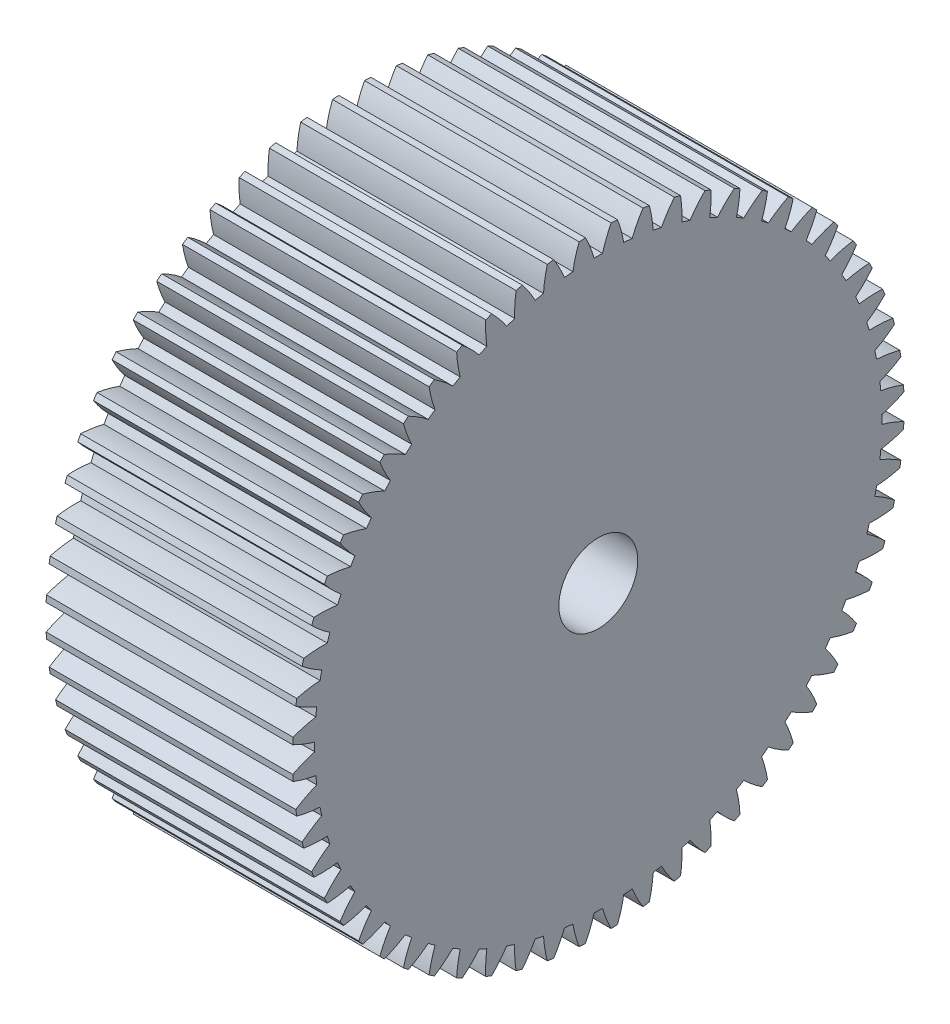
from build123d import *

# Parameters (mm, degrees)
BASPROSKE_W     = 25
BASPROSKE_H     = 31
TOOTHCUT_DEPTH  = 51.467811524
TEETHCUTS_COUNT = 60
TEETHCUTS_ANGLE = 354
BORSKE_R        = 4
BORE_DEPTH      = 50.0000508


with BuildPart() as part:
    # BasProSke → Base-Revolve (revolve)
    with BuildSketch(Plane(origin=(0, 0, 0), x_dir=(1, 0, 0), z_dir=(0, 1, 0)), mode=Mode.PRIVATE) as base_revolve_sk:
        with Locations((12.5, 15.5)):
            Rectangle(BASPROSKE_W, BASPROSKE_H)
    revolve(base_revolve_sk.sketch.rotate(Axis((-10, 0, 0), (1, 0, 0)), 180), axis=Axis((-10, 0, 0), (1, 0, 0)))

    # TooCutSke → ToothCut (cut, through all)
    with BuildSketch(Plane(origin=(0, 0, 0), x_dir=(0, 0, -1), z_dir=(1, 0, 0))):
        with BuildLine():
            ThreePointArc((0.430151971, 28.745781782), (0, 28.749), (-0.430151971, 28.745781782))
            ThreePointArc((-0.430151971, 28.745781782), (-0.81454129, 29.893990802), (-1.312684569, 30.997617721))
            ThreePointArc((-1.312684569, 30.997617721), (0, 31.0254), (1.312684569, 30.997617721))
            ThreePointArc((1.312684569, 30.997617721), (0.81454129, 29.893990802), (0.430151971, 28.745781782))
        make_face()
    toothcut = extrude(amount=TOOTHCUT_DEPTH, mode=Mode.SUBTRACT)

    # TeethCuts: ToothCut ×60 about axis
    teethcuts_axis = Axis((-10, 0, 0), (1, 0, 0))
    for i in range(1, TEETHCUTS_COUNT):
        add(toothcut.rotate(teethcuts_axis, i * TEETHCUTS_ANGLE / (TEETHCUTS_COUNT - 1)), mode=Mode.SUBTRACT)

    # BorSke → Bore (cut, symmetric)
    with BuildSketch(Plane(origin=(0, 0, 0), x_dir=(0, 0, -1), z_dir=(1, 0, 0))):
        with Locations(Location((0, 0, 0), (0, 0, 180))):
            Circle(BORSKE_R)
    extrude(amount=BORE_DEPTH, both=True, mode=Mode.SUBTRACT)


solid = part.part
